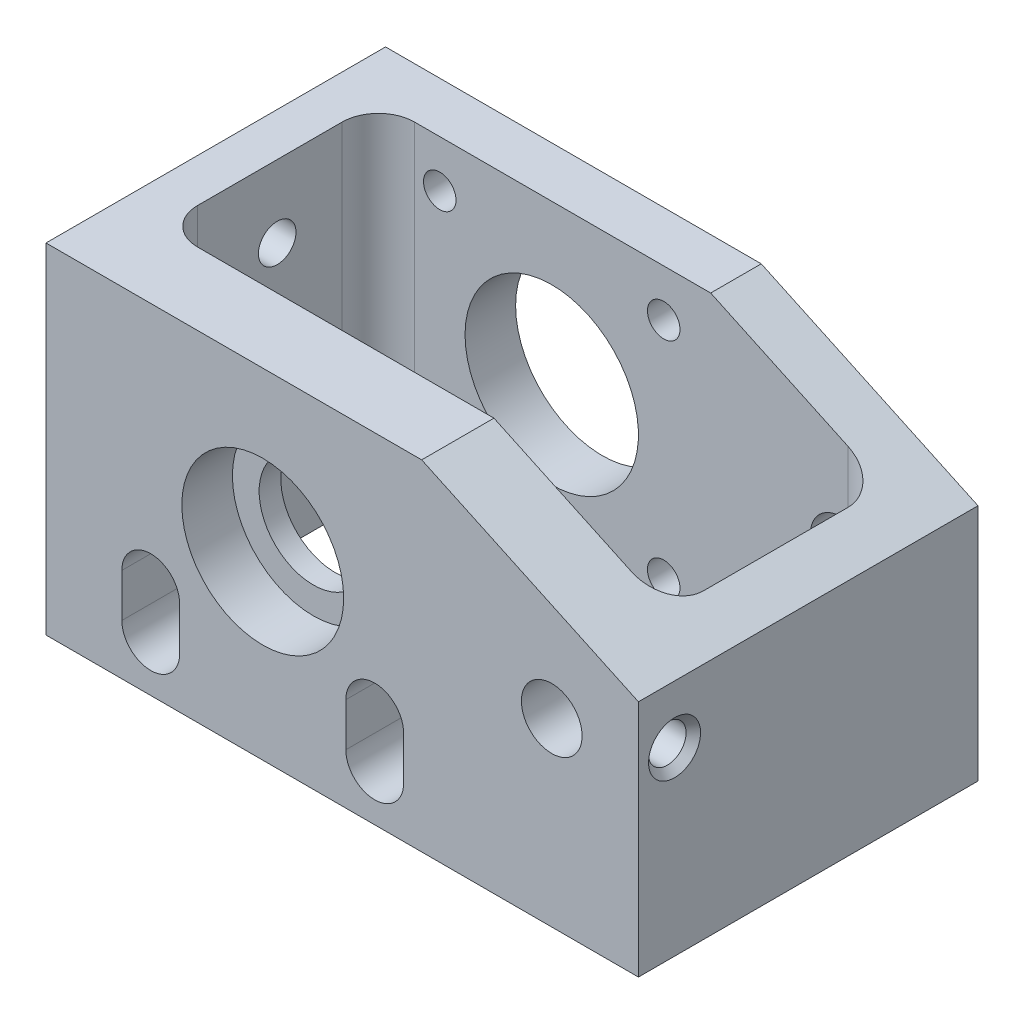
from build123d import *

# Parameters (mm, degrees)
SKETCH1_R           = 7.5
SKETCH1_R_2         = 4.2
BOSS_EXTRUDE1_DEPTH = 47
SKETCH2_R           = 11.2
CUT_EXTRUDE1_DEPTH  = 7
SKETCH3_R           = 2.25
SKETCH3_R_2         = 12
CUT_EXTRUDE2_DEPTH  = 15
CUT_EXTRUDE3_DEPTH  = 48
CUT_EXTRUDE4_DEPTH  = 20
SKETCH7_R           = 2.6
CUT_EXTRUDE5_DEPTH  = 10
SKETCH8_R           = 2.6
CUT_EXTRUDE6_DEPTH  = 8
CHAMFER1_SIZE       = 1
SKETCH9_R           = 2.6
CUT_EXTRUDE7_DEPTH  = 10
CHAMFER2_SIZE       = 1


with BuildPart() as part:
    # Sketch1 → Boss-Extrude1 (new body)
    with BuildSketch(Plane.XY):
        Polygon((-30, -25), (-30, 22), (22, 22), (52, 8), (52, -25), align=None)
        Circle(SKETCH1_R, mode=Mode.SUBTRACT)
        with Locations((40, 0)):
            Circle(SKETCH1_R_2, mode=Mode.SUBTRACT)
    extrude(amount=BOSS_EXTRUDE1_DEPTH)

    # Sketch2 → Cut-Extrude1 (cut)
    with BuildSketch(Plane.XY.offset(47)):
        Circle(SKETCH2_R)
    extrude(amount=-CUT_EXTRUDE1_DEPTH, mode=Mode.SUBTRACT)

    # Sketch3 → Cut-Extrude2 (cut)
    with BuildSketch(Plane(origin=(0, 0, 0), x_dir=(-1, 0, 0), z_dir=(0, 0, -1))):
        with Locations((-15.5, 15.5)):
            Circle(SKETCH3_R)
        with Locations((-15.5, -15.5)):
            Circle(SKETCH3_R)
        with Locations((15.5, -15.5)):
            Circle(SKETCH3_R)
        with Locations((15.5, 15.5)):
            Circle(SKETCH3_R)
        Circle(SKETCH3_R_2)
    extrude(amount=-CUT_EXTRUDE2_DEPTH, mode=Mode.SUBTRACT)

    # Sketch4 → Cut-Extrude3 (cut, through all)
    with BuildSketch(Plane(origin=(0, 22, 0), x_dir=(1, 0, 0), z_dir=(0, 1, 0))):
        with BuildLine():
            Line((-19, -7), (41, -7))
            ThreePointArc((41, -7), (44.535533906, -8.464466094), (46, -12))
            Line((46, -12), (46, -32))
            ThreePointArc((46, -32), (44.535533906, -35.535533906), (41, -37))
            Line((41, -37), (-19, -37))
            ThreePointArc((-19, -37), (-22.535533906, -35.535533906), (-24, -32))
            Line((-24, -32), (-24, -12))
            ThreePointArc((-24, -12), (-22.535533906, -8.464466094), (-19, -7))
        make_face()
    extrude(amount=-CUT_EXTRUDE3_DEPTH, mode=Mode.SUBTRACT)

    # Sketch6 → Cut-Extrude4 (cut)
    with BuildSketch(Plane.XY.offset(47)):
        with BuildLine():
            Line((-19.5, -12), (-19.5, -18))
            ThreePointArc((-19.5, -18), (-15.5, -22), (-11.5, -18))
            Line((-11.5, -18), (-11.5, -12))
            ThreePointArc((-11.5, -12), (-15.5, -8), (-19.5, -12))
        make_face()
        with BuildLine():
            Line((11.5, -12), (11.5, -18))
            ThreePointArc((11.5, -18), (15.5, -22), (19.5, -18))
            Line((19.5, -18), (19.5, -12))
            ThreePointArc((19.5, -12), (15.5, -8), (11.5, -12))
        make_face()
    extrude(amount=-CUT_EXTRUDE4_DEPTH, mode=Mode.SUBTRACT)

    # Sketch7 → Cut-Extrude5 (cut)
    with BuildSketch(Plane(origin=(52, 0, 0), x_dir=(0, 0, -1), z_dir=(1, 0, 0))):
        with Locations(Location((-42, 0, 0), (0, 0, 90))):  # turned: the seam where the file's is
            Circle(SKETCH7_R)
    extrude(amount=-CUT_EXTRUDE5_DEPTH, mode=Mode.SUBTRACT)

    # Sketch8 → Cut-Extrude6 (cut)
    with BuildSketch(Plane.XZ.offset(25)):
        with Locations((-25, 42)):
            Circle(SKETCH8_R)
        with Locations((-25, 5)):
            Circle(SKETCH8_R)
        with Locations((47, 5)):
            Circle(SKETCH8_R)
        with Locations((47, 42)):
            Circle(SKETCH8_R)
    extrude(amount=-CUT_EXTRUDE6_DEPTH, mode=Mode.SUBTRACT)

    # Chamfer1
    chamfer1_edges = [part.edges().sort_by_distance(p)[0] for p in [
        (-27.6, -25, 42),
        (-27.6, -25, 5),
        (44.4, -25, 5),
        (44.4, -25, 42),
    ]]
    chamfer(chamfer1_edges, length=CHAMFER1_SIZE)

    # Sketch9 → Cut-Extrude7 (cut)
    with BuildSketch(Plane.ZY.offset(30)):
        with Locations((41, 12)):
            Circle(SKETCH9_R)
        with Locations((21, 12)):
            Circle(SKETCH9_R)
    extrude(amount=-CUT_EXTRUDE7_DEPTH, mode=Mode.SUBTRACT)

    # Chamfer2
    chamfer2_edges = [part.edges().sort_by_distance(p)[0] for p in [
        (52, -2.6, 42),
    ]]
    chamfer(chamfer2_edges, length=CHAMFER2_SIZE)


solid = part.part
